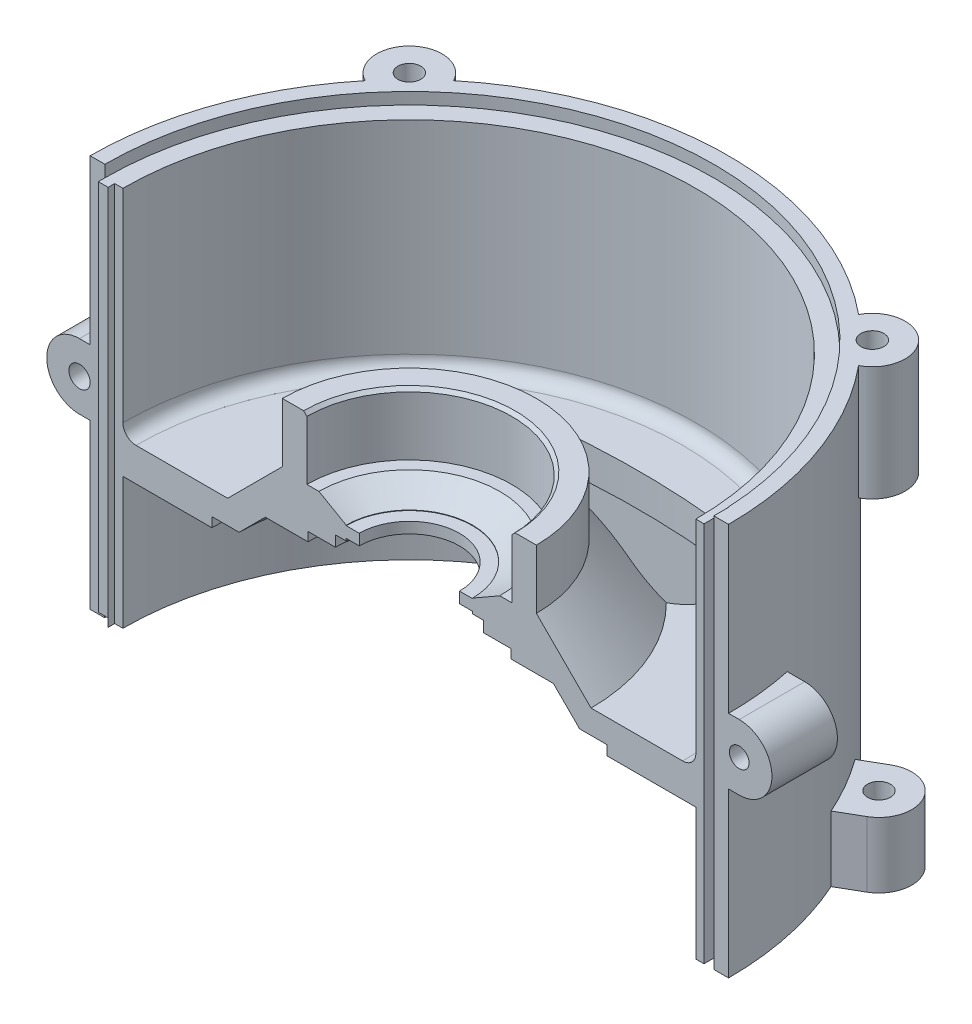
from build123d import *

# Parameters (mm, degrees)
REVOLU_O2_ANGLE          = 180
ESBO_O4_R                = 10
RESSALTO_EXTRUS_O1_DEPTH = 35
RESSALTO_EXTRUS_O2_DEPTH = 20
ESBO_O8_R                = 3.5
CORTE_EXTRUS_O2_DEPTH    = 20
PADR_OCIRCULAR1_COUNT    = 6
ESBO_O6_R                = 3.5
CORTE_EXTRUS_O1_DEPTH    = 15
ESBO_O9_R                = 1.25
CORTE_EXTRUS_O3_DEPTH    = 6
ESBO_O10_W               = 3
ESBO_O10_H               = 120
CORTE_EXTRUS_O4_DEPTH    = 4.5
ESBO_O11_W               = 3
ESBO_O11_H               = 116.4
RESSALTO_EXTRUS_O5_DEPTH = 2
ESBO_O12_R               = 3.25
RESSALTO_EXTRUS_O6_DEPTH = 20
ESBO_O13_R               = 3
RESSALTO_EXTRUS_O7_DEPTH = 20
CORTE_EXTRUS_O5_DEPTH    = 80.8
ESBO_O16_R               = 93
CORTE_EXTRUS_O6_DEPTH    = 10
ESBO_O17_R               = 93.112429775
ESBO_O17_R_2             = 90.112429775
CORTE_EXTRUS_O7_DEPTH    = 2.5
ESBO_O18_W               = 100
ESBO_O18_H               = 17.238697901
CORTE_EXTRUS_O8_DEPTH    = 15
RESSALTO_EXTRUS_O9_DEPTH = 15


with BuildPart() as part:
    # Esboço3 → Revolução2 (revolve)
    with BuildSketch(Plane.XY):
        with BuildLine():
            Line((97.5, 79.8), (97.5, 11.304491341))
            Line((97.5, 11.304491341), (97.5, 0))
            Line((97.5, 0), (97.5, -40.2))
            Line((97.5, -40.2), (87.5, -40.2))
            Line((87.5, -40.2), (87.5, 0))
            Line((87.5, 0), (60.342408243, 0))
            Line((60.342408243, 0), (60.342408243, 2.95))
            Line((60.342408243, 2.95), (52, 2.95))
            Line((52, 2.95), (44, 10.95))
            Line((44, 10.95), (31, 10.95))
            Line((31, 10.95), (31, 13.7))
            Line((31, 13.7), (22.6, 13.7))
            Line((22.6, 13.7), (22.6, 17))
            Line((22.6, 17), (19.3, 17))
            Line((19.3, 17), (19.3, 17.7))
            Line((19.3, 17.7), (15.3, 17.7))
            Line((15.3, 17.7), (15.3, 21.05))
            Line((15.3, 21.05), (19.3, 21.05))
            Line((19.3, 21.05), (19.3, 21.2))
            Line((19.3, 21.2), (27.626549127, 25.96))
            Line((27.626549127, 25.96), (31.3, 25.96))
            Line((31.3, 25.96), (31.3, 43.96))
            Line((31.3, 43.96), (32.3, 44.96))
            Line((32.3, 44.96), (38.8, 44.96))
            Line((38.8, 44.96), (38.8, 26.9))
            Line((38.8, 26.9), (55.5, 10.2))
            Line((55.5, 10.2), (83.5, 10.2))
            ThreePointArc((83.5, 10.2), (86.328427125, 11.371572875), (87.5, 14.2))
            Line((87.5, 14.2), (87.5, 76.2))
            Line((87.5, 76.2), (93, 76.2))
            Line((93, 76.2), (93, 79.8))
            Line((93, 79.8), (97.5, 79.8))
        make_face()
    revolve(axis=Axis((0, -3.322055656, 0), (0, 1, 0)), revolution_arc=REVOLU_O2_ANGLE)

    # Esboço4 → Ressalto-extrusão1 (add)
    with BuildSketch(Plane(origin=(0, 79.8, 0), x_dir=(1, 0, 0), z_dir=(0, 1, 0))):
        with Locations((70.71, 70.71)):
            Circle(ESBO_O4_R)
        with Locations((-70.71, 70.71)):
            Circle(ESBO_O4_R)
    extrude(amount=-RESSALTO_EXTRUS_O1_DEPTH)

    # Esboço5 → Ressalto-extrusão2 (add)
    with BuildSketch(Plane.XZ.offset(40.2)):
        with BuildLine():
            Line((10, -105), (10, -96.985823706))
            Line((10, -96.985823706), (-10, -96.985823706))
            Line((-10, -96.985823706), (-10, -105))
            ThreePointArc((-10, -105), (0, -115), (10, -105))
        make_face()
    ressalto_extrus_o2 = extrude(amount=-RESSALTO_EXTRUS_O2_DEPTH)

    # Esboço8 → Corte-extrusão2 (cut)
    with BuildSketch(Plane.XZ.offset(40.2)):
        with Locations((0, -105)):
            Circle(ESBO_O8_R)
    corte_extrus_o2 = extrude(amount=-CORTE_EXTRUS_O2_DEPTH, mode=Mode.SUBTRACT)

    # PadrãoCircular1: Ressalto-extrusão2, Corte-extrusão2 ×6 about axis, 3 skipped
    padr_ocircular1_axis = Axis((0, 0, 0), (0, 1, 0))
    add([ressalto_extrus_o2.rotate(padr_ocircular1_axis, i * 360 / PADR_OCIRCULAR1_COUNT) for i in range(1, PADR_OCIRCULAR1_COUNT) if i not in (2, 3, 4)])
    add([corte_extrus_o2.rotate(padr_ocircular1_axis, i * 360 / PADR_OCIRCULAR1_COUNT) for i in range(1, PADR_OCIRCULAR1_COUNT) if i not in (2, 3, 4)], mode=Mode.SUBTRACT)

    # Esboço6 → Corte-extrusão1 (cut)
    with BuildSketch(Plane(origin=(0, 79.8, 0), x_dir=(1, 0, 0), z_dir=(0, 1, 0))):
        with Locations((70.71, 70.71)):
            Circle(ESBO_O6_R)
        with Locations((-70.71, 70.71)):
            Circle(ESBO_O6_R)
    extrude(amount=-CORTE_EXTRUS_O1_DEPTH, mode=Mode.SUBTRACT)

    # Esboço9 → Corte-extrusão3 (cut)
    with BuildSketch(Plane.XZ.offset(-13.7)):
        with Locations((18.738329701, -18.738329701)):
            Circle(ESBO_O9_R)
        with Locations((-18.738329701, -18.738329701)):
            Circle(ESBO_O9_R)
    extrude(amount=-CORTE_EXTRUS_O3_DEPTH, mode=Mode.SUBTRACT)

    # Esboço10 → Corte-extrusão4 (cut)
    with BuildSketch(Plane.XY):
        with Locations((91.5, 19.8)):
            Rectangle(ESBO_O10_W, ESBO_O10_H)
    extrude(amount=-CORTE_EXTRUS_O4_DEPTH, mode=Mode.SUBTRACT)

    # Esboço11 → Ressalto-extrusão5 (add)
    with BuildSketch(Plane.XY):
        with Locations((-91.5, 18)):
            Rectangle(ESBO_O11_W, ESBO_O11_H)
    extrude(amount=RESSALTO_EXTRUS_O5_DEPTH)

    # Esboço12 → Ressalto-extrusão6 (add)
    with BuildSketch(Plane.XY):
        with BuildLine():
            Line((-100.75, 29.8), (-87.5, 29.8))
            Line((-87.5, 29.8), (-87.5, 9.8))
            Line((-87.5, 9.8), (-100.75, 9.8))
            ThreePointArc((-100.75, 9.8), (-110.75, 19.8), (-100.75, 29.8))
        make_face()
        with Locations((-100.75, 19.8)):
            Circle(ESBO_O12_R, mode=Mode.SUBTRACT)
    extrude(amount=-RESSALTO_EXTRUS_O6_DEPTH)

    # Esboço13 → Ressalto-extrusão7 (add)
    with BuildSketch(Plane.XY):
        with BuildLine():
            Line((100.75, 29.8), (93, 29.8))
            Line((93, 29.8), (93, 9.8))
            Line((93, 9.8), (100.75, 9.8))
            ThreePointArc((100.75, 9.8), (110.75, 19.8), (100.75, 29.8))
        make_face()
        with Locations((100.75, 19.8)):
            Circle(ESBO_O13_R, mode=Mode.SUBTRACT)
    extrude(amount=-RESSALTO_EXTRUS_O7_DEPTH)

    # Esboço14 → Corte-extrusão5 (cut, through all)
    with BuildSketch(Plane(origin=(0, 0, 0), x_dir=(-1, 0, 0), z_dir=(0, -1, 0))):
        with BuildLine():
            ThreePointArc((34.350508428, 67.496062714), (0, 70), (-34.350508428, 67.496062714))
            ThreePointArc((-34.350508428, 67.496062714), (-47.016691783, 50.479370931), (-30, 37.813187576))
            ThreePointArc((-30, 37.813187576), (0, 40), (30, 37.813187576))
            ThreePointArc((30, 37.813187576), (47.016691783, 50.479370931), (34.350508428, 67.496062714))
        make_face()
    extrude(amount=-CORTE_EXTRUS_O5_DEPTH, mode=Mode.SUBTRACT)

    # Esboço16 → Corte-extrusão6 (cut)
    with BuildSketch(Plane(origin=(0, 76.2, 0), x_dir=(1, 0, 0), z_dir=(0, 1, 0))):
        Circle(ESBO_O16_R)
    extrude(amount=CORTE_EXTRUS_O6_DEPTH, mode=Mode.SUBTRACT)

    # Esboço17 → Corte-extrusão7 (cut)
    with BuildSketch(Plane.XZ.offset(40.2)):
        Circle(ESBO_O17_R)
        Circle(ESBO_O17_R_2, mode=Mode.SUBTRACT)
    extrude(amount=-CORTE_EXTRUS_O7_DEPTH, mode=Mode.SUBTRACT)

    # Esboço18 → Corte-extrusão8 (cut, symmetric)
    with BuildSketch(Plane(origin=(0, -20.1, 0), x_dir=(-1, 0, 0), z_dir=(0, -1, 0))):
        with Locations((0, 72.662310295)):
            Rectangle(ESBO_O18_W, ESBO_O18_H)
    extrude(amount=CORTE_EXTRUS_O8_DEPTH, both=True, mode=Mode.SUBTRACT)

    # Esboço19 → Ressalto-extrusão9 (add, symmetric)
    with BuildSketch(Plane(origin=(0, -20.1, 0), x_dir=(-1, 0, 0), z_dir=(0, -1, 0))):
        with BuildLine():
            Line((32.396633626, 81.281659245), (-32.396633626, 81.281659245))
            ThreePointArc((-32.396633626, 81.281659245), (0, 87.5), (32.396633626, 81.281659245))
        make_face()
    extrude(amount=RESSALTO_EXTRUS_O9_DEPTH, both=True)


solid = part.part
